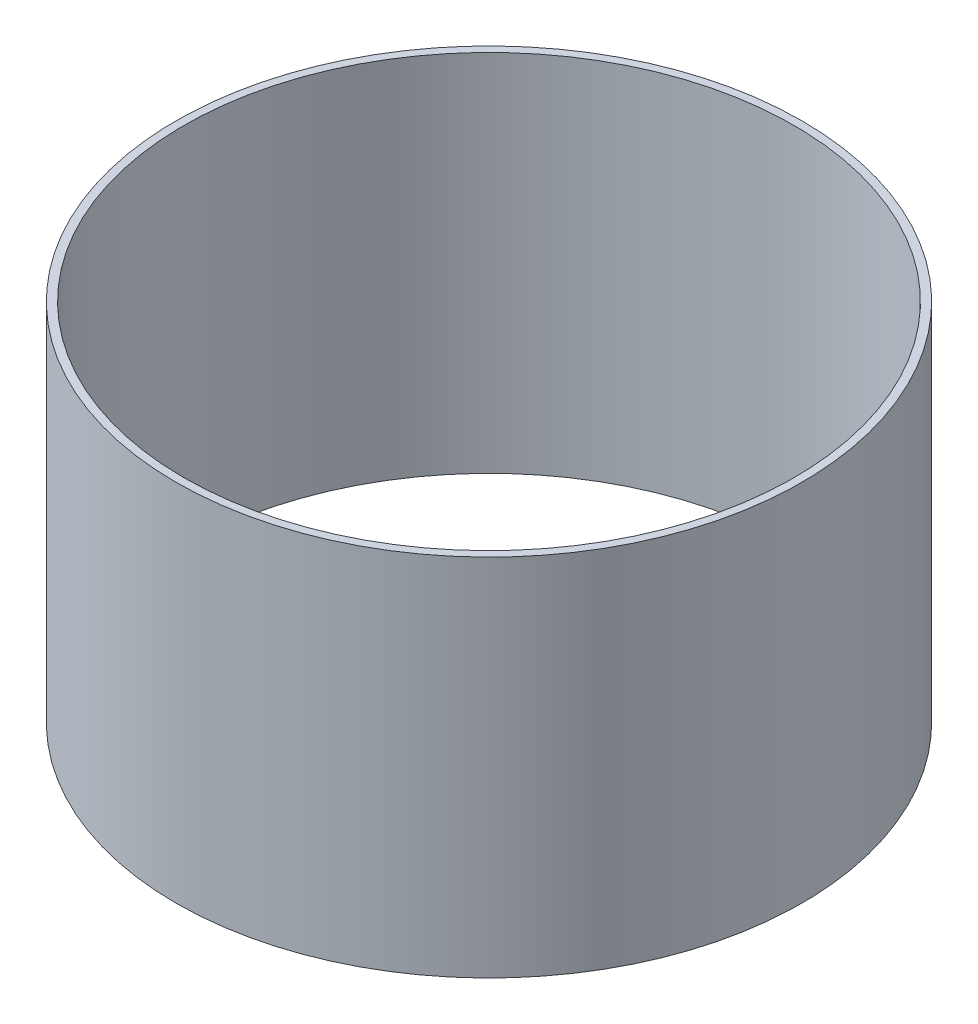
from build123d import *

# Parameters (mm, degrees)
SKETCH1_R           = 79
SKETCH1_R_2         = 77
BOSS_EXTRUDE1_DEPTH = 92


with BuildPart() as part:
    # Sketch1 → Boss-Extrude1 (new body)
    with BuildSketch(Plane(origin=(0, 0, 0), x_dir=(1, 0, 0), z_dir=(0, 1, 0))):
        Circle(SKETCH1_R)
        Circle(SKETCH1_R_2, mode=Mode.SUBTRACT)
    extrude(amount=BOSS_EXTRUDE1_DEPTH)


solid = part.part
